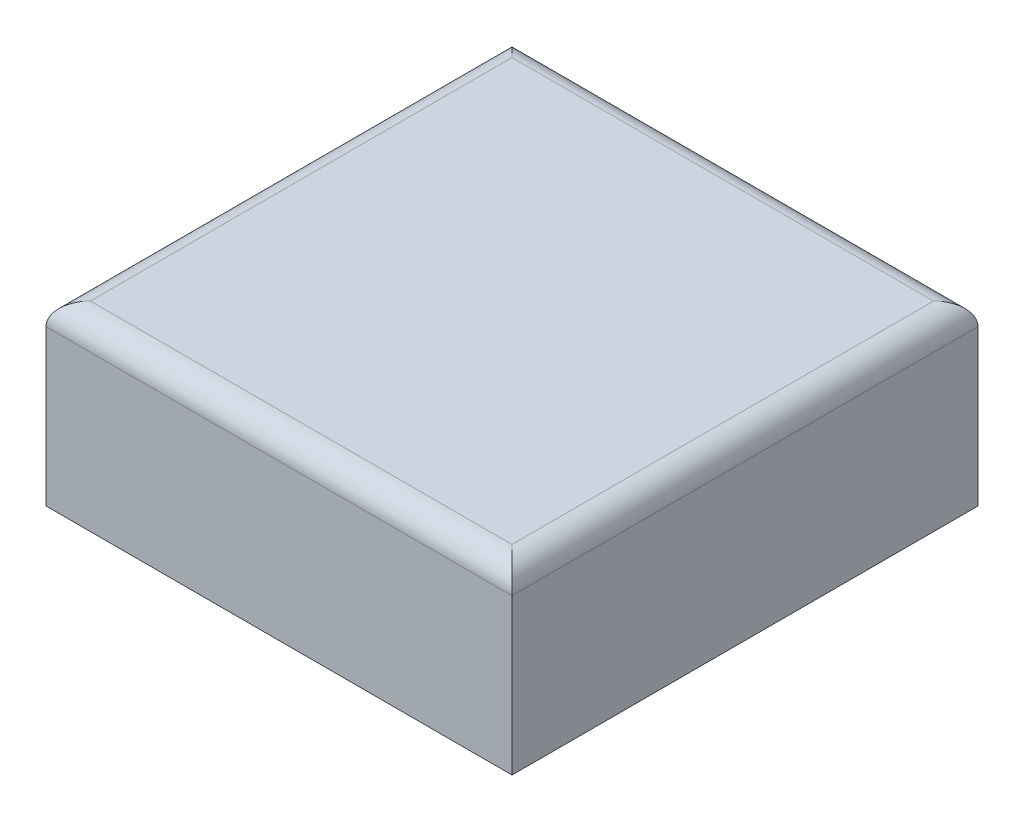
from build123d import *

# Parameters (mm, degrees)
SKETCH1_W           = 21
SKETCH1_H           = 21
BOSS_EXTRUDE1_DEPTH = 8
FILLET1_R           = 1


with BuildPart() as part:
    # Sketch1 → Boss-Extrude1 (new body)
    with BuildSketch(Plane(origin=(0, 0, 0), x_dir=(1, 0, 0), z_dir=(0, 1, 0))):
        Rectangle(SKETCH1_W, SKETCH1_H)
    extrude(amount=BOSS_EXTRUDE1_DEPTH)

    # Fillet1
    fillet1_edges = [part.edges().sort_by_distance(p)[0] for p in [
        (-10.5, 8, 0),
        (0, 8, 10.5),
        (10.5, 8, 0),
        (0, 8, -10.5),
    ]]
    fillet(fillet1_edges, radius=FILLET1_R)


solid = part.part
